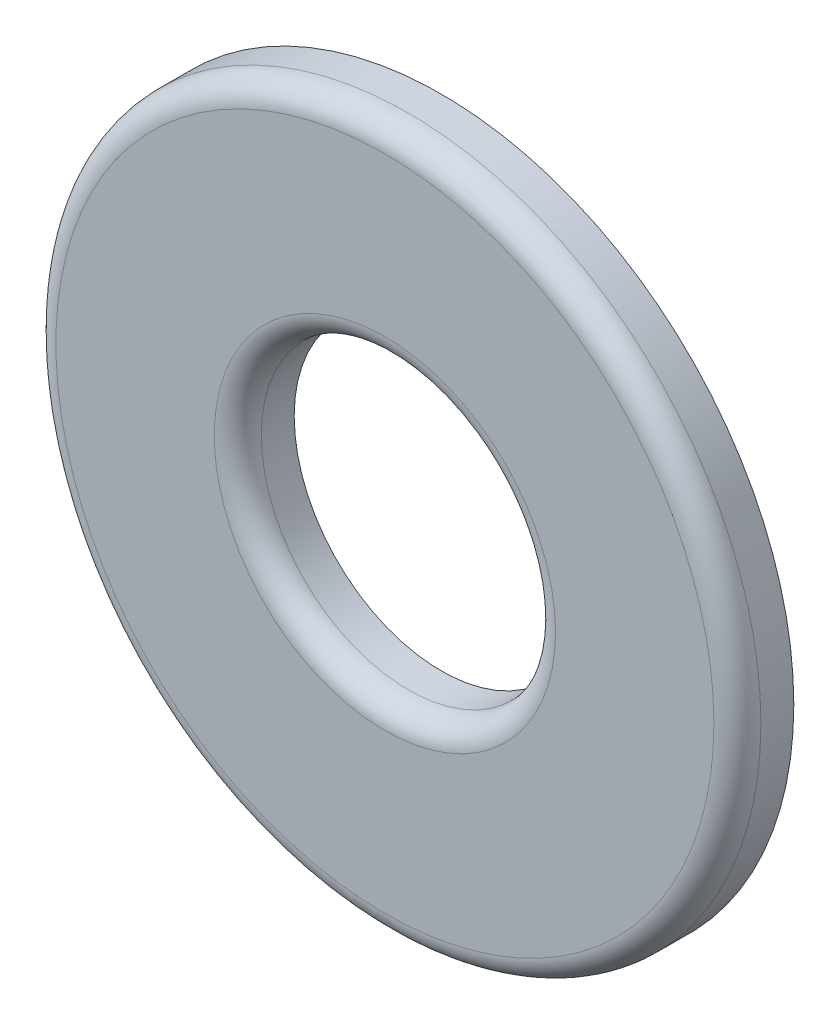
from build123d import *

# Parameters (mm, degrees)
SKETCH1_R           = 9.525
SKETCH1_R_2         = 3.9751
BOSS_EXTRUDE1_DEPTH = 1.524
FILLET1_R           = 0.635


with BuildPart() as part:
    # Sketch1 → Boss-Extrude1 (new body)
    with BuildSketch(Plane.XY):
        Circle(SKETCH1_R)
        Circle(SKETCH1_R_2, mode=Mode.SUBTRACT)
    extrude(amount=BOSS_EXTRUDE1_DEPTH)

    # Fillet1
    fillet1_edges = [part.edges().sort_by_distance(p)[0] for p in [
        (-9.525, 0, 1.524),
        (-3.9751, 0, 1.524),
    ]]
    fillet(fillet1_edges, radius=FILLET1_R)


solid = part.part
